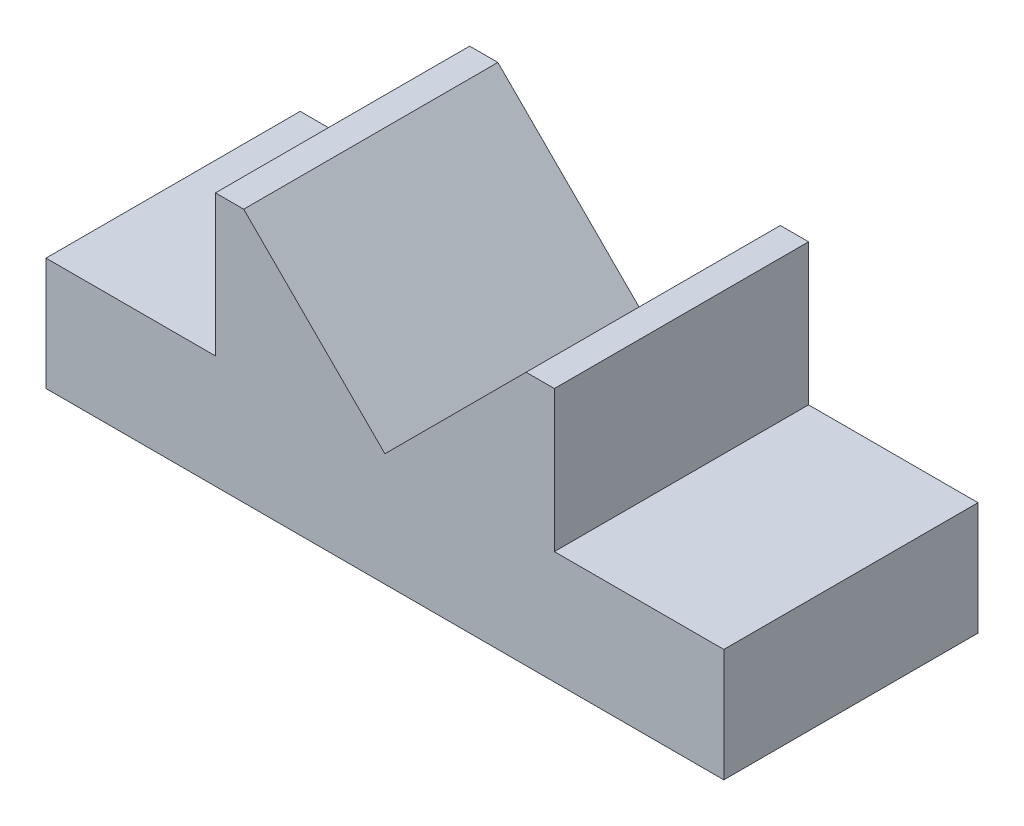
from build123d import *

# Parameters (mm, degrees)
BOSS_EXTRUDE1_DEPTH = 45


with BuildPart() as part:
    # Sketch1 → Boss-Extrude1 (new body)
    with BuildSketch(Plane.XY):
        Polygon((60, 0), (-60, 0), (-60, 20), (-30, 20), (-30, 45), (-25, 45), (0, 20), (25, 45), (30, 45), (30, 20), (60, 20), align=None)
    extrude(amount=BOSS_EXTRUDE1_DEPTH)


solid = part.part
